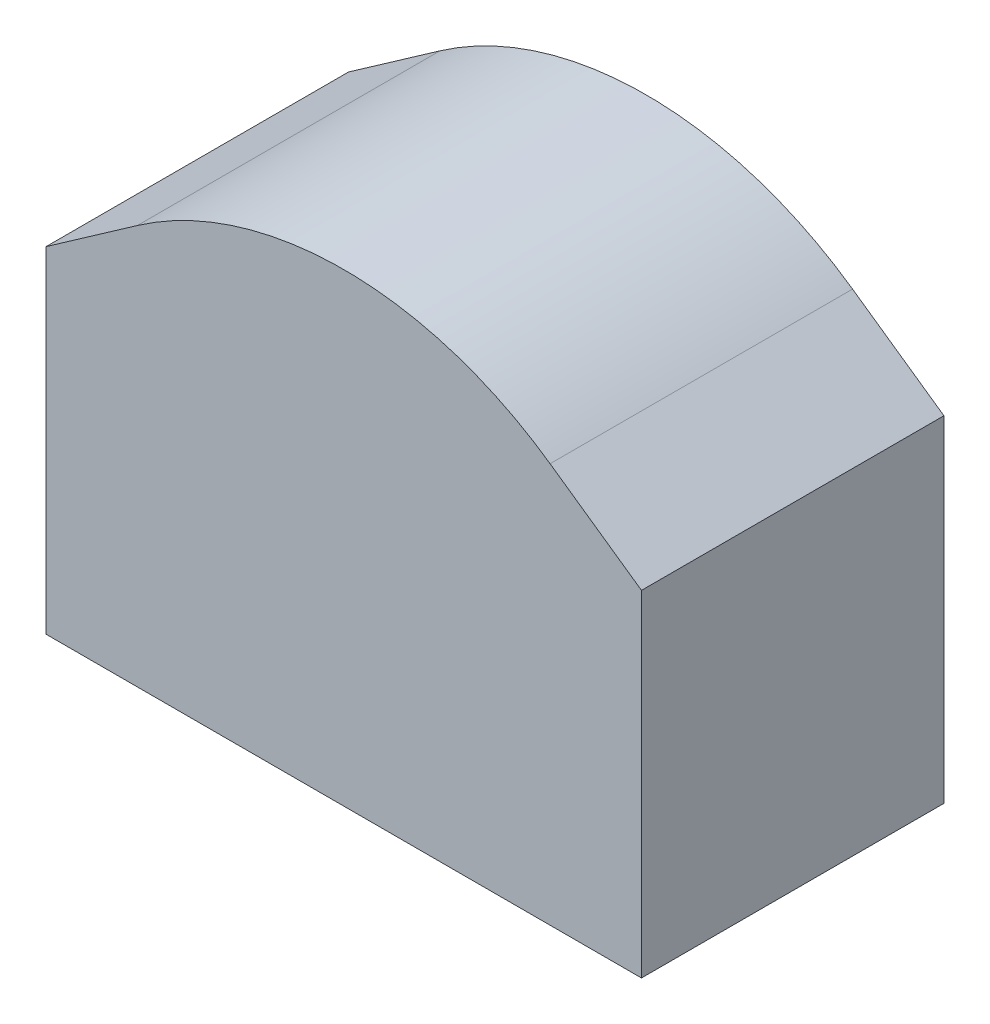
from build123d import *

# Parameters (mm, degrees)
BOSS_EXTRUDE1_DEPTH = 2.54


with BuildPart() as part:
    # Sketch1 → Boss-Extrude1 (new body)
    with BuildSketch(Plane.XY):
        with BuildLine():
            Line((-2.5, -0.88204324), (2.5, -0.88204324))
            Line((2.5, -0.88204324), (2.5, 1.937019723))
            Line((2.5, 1.937019723), (1.732576391, 2.474375519))
            ThreePointArc((1.732576391, 2.474375519), (1.312078864, 2.720809477), (0.857422044, 2.896408569))
            ThreePointArc((0.857422044, 2.896408569), (0, 3.020654757), (-0.857422044, 2.896408569))
            ThreePointArc((-0.857422044, 2.896408569), (-1.312078864, 2.720809477), (-1.732576391, 2.474375519))
            Line((-1.732576391, 2.474375519), (-2.5, 1.937019723))
            Line((-2.5, 1.937019723), (-2.5, -0.88204324))
        make_face()
    extrude(amount=BOSS_EXTRUDE1_DEPTH)


solid = part.part
